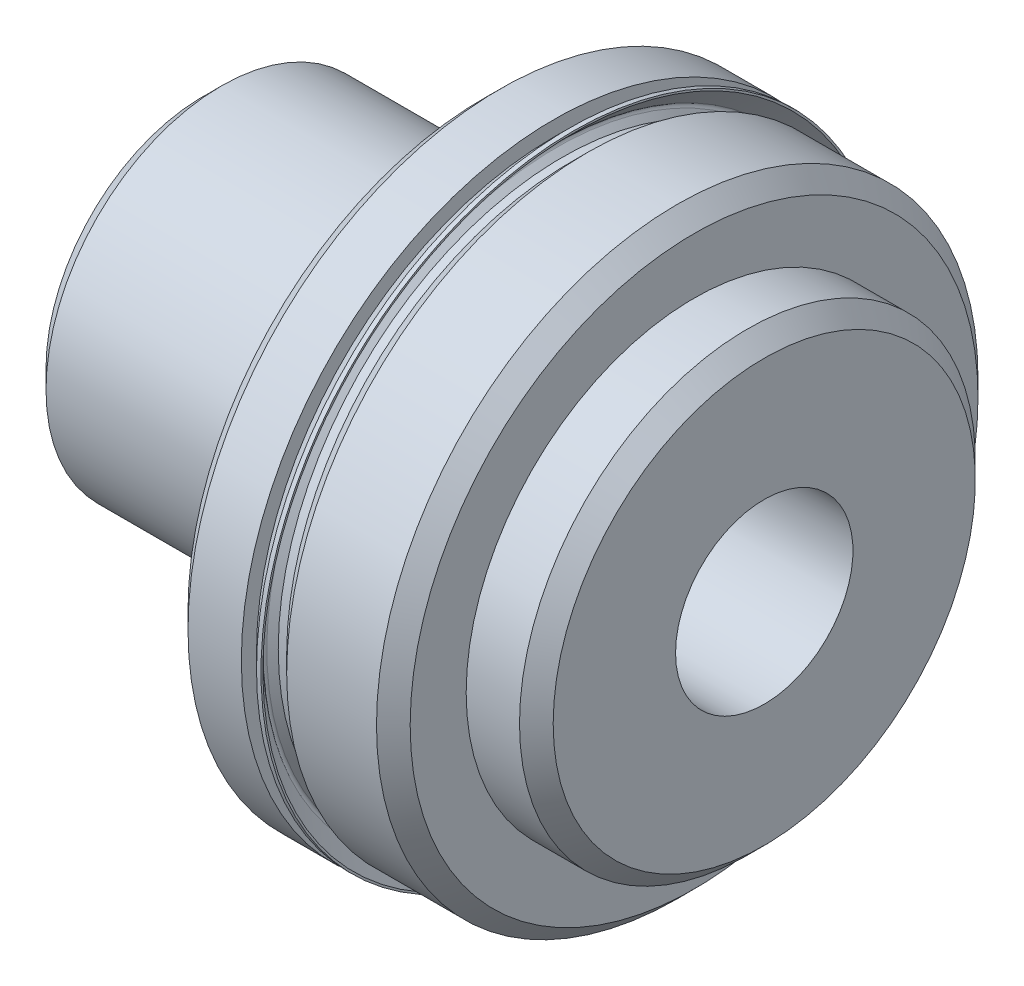
from build123d import *

# Parameters (mm, degrees)
HOLE1_D           = 8.0264
HOLE1_CSINK_D     = 9.5504
HOLE1_CSINK_ANGLE = 90


with BuildPart() as part:
    # Sketch1 → Revolve1 (revolve)
    with BuildSketch(Plane.XY):
        Polygon((0, 0), (0, 7.09803), (0.83947, 7.9375), (12.7, 7.9375), (12.7, 0), align=None)
    revolve(axis=Axis((12.7, 0, 0), (-1, 0, 0)))

    # Sketch2 → Revolve2 (revolve)
    with BuildSketch(Plane.XY):
        Polygon((12.7, 0), (12.7, 13.3731), (13.462, 14.1351), (15.875, 14.1351), (15.875, 12.84605), (16.637, 12.84605), (17.399, 13.60805), (21.463, 13.60805), (22.225, 12.84605), (22.225, 0), align=None)
    revolve(axis=Axis((22.225, 0, 0), (-1, 0, 0)))

    # Sketch3 → Revolve3 (revolve)
    with BuildSketch(Plane.XY):
        Polygon((22.225, 0), (22.225, 10.3124), (24.638, 10.3124), (25.4, 9.5504), (25.4, 0), align=None)
    revolve(axis=Axis((25.4, 0, 0), (-1, 0, 0)))

    # Hole1 (through all)
    with Locations(Plane.ZY):
        with Locations((0, 0)):
            CounterSinkHole(HOLE1_D / 2, HOLE1_CSINK_D / 2, counter_sink_angle=HOLE1_CSINK_ANGLE)

    # Sketch6 → Revolve4 (revolve)
    with BuildSketch(Plane.XY):
        with BuildLine():
            Line((15.875, 12.59205), (16.637, 12.59205))
            Line((16.637, 12.59205), (16.637, 12.84605))
            Line((16.637, 12.84605), (16.256, 12.84605))
            Line((16.256, 12.84605), (15.997487194, 13.104562806))
            ThreePointArc((15.997487194, 13.104562806), (15.960289755, 13.194365367), (15.997487194, 13.284167928))
            Line((15.997487194, 13.284167928), (16.76425107, 14.050931804))
            Line((16.76425107, 14.050931804), (16.76425107, 14.1351))
            Line((16.76425107, 14.1351), (16.56105107, 14.1351))
            Line((16.56105107, 14.1351), (15.875, 13.44904893))
            Line((15.875, 13.44904893), (15.875, 12.59205))
        make_face()
    revolve(axis=Axis((16.637, 0, 0), (-1, 0, 0)))


solid = part.part
